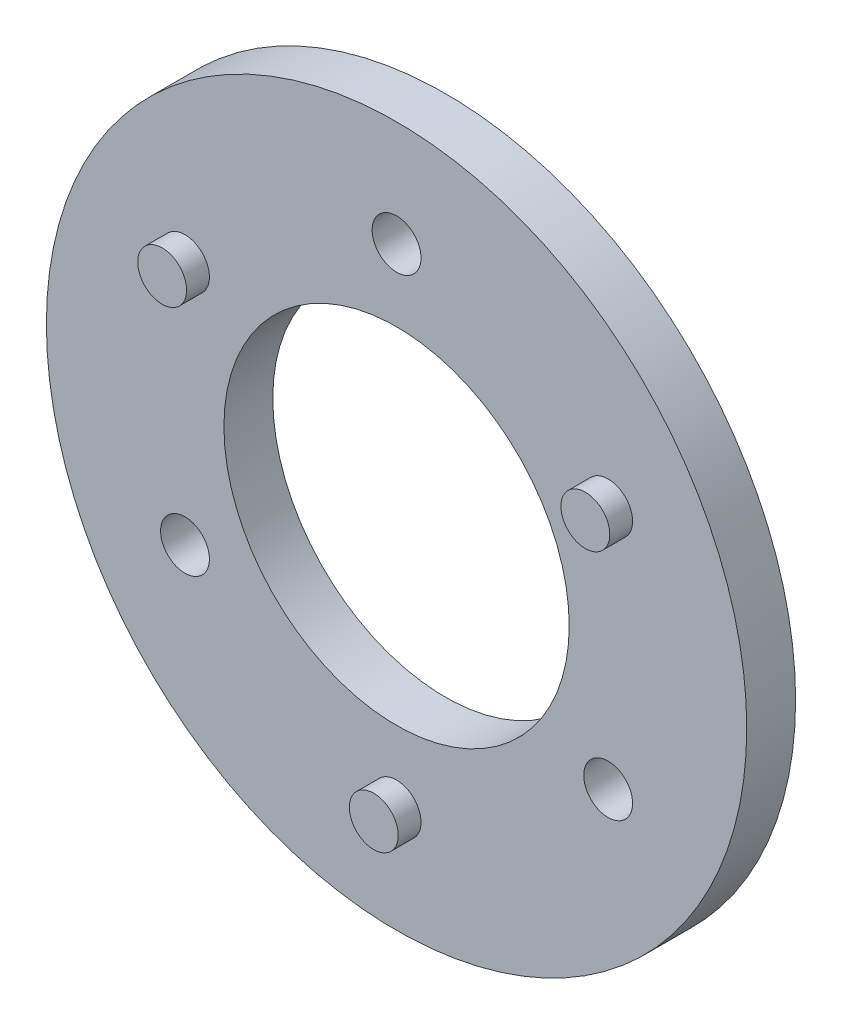
from build123d import *

# Parameters (mm, degrees)
SKETCH_1_R      = 21.5
SKETCH_1_R_2    = 10.6
SKETCH_1_R_3    = 1.5
EXTRUDE_1_DEPTH = 3
SKETCH_2_R      = 1.5
EXTRUDE_2_DEPTH = 1.4


with BuildPart() as part:
    # 草圖1 → 填料-伸長1 (new body)
    with BuildSketch(Plane.XY):
        Circle(SKETCH_1_R)
        Circle(SKETCH_1_R_2, mode=Mode.SUBTRACT)
        with Locations((0, 15)):
            Circle(SKETCH_1_R_3, mode=Mode.SUBTRACT)
        with Locations((12.990381057, -7.5)):
            Circle(SKETCH_1_R_3, mode=Mode.SUBTRACT)
        with Locations((-12.990381057, -7.5)):
            Circle(SKETCH_1_R_3, mode=Mode.SUBTRACT)
    extrude(amount=EXTRUDE_1_DEPTH)

    # 草圖2 → 填料-伸長2 (add)
    with BuildSketch(Plane.XY.offset(3)):
        with Locations((12.990381057, 7.5)):
            Circle(SKETCH_2_R)
        with Locations((-12.990381057, 7.5)):
            Circle(SKETCH_2_R)
        with Locations((0, -15)):
            Circle(SKETCH_2_R)
    extrude(amount=EXTRUDE_2_DEPTH)


solid = part.part
